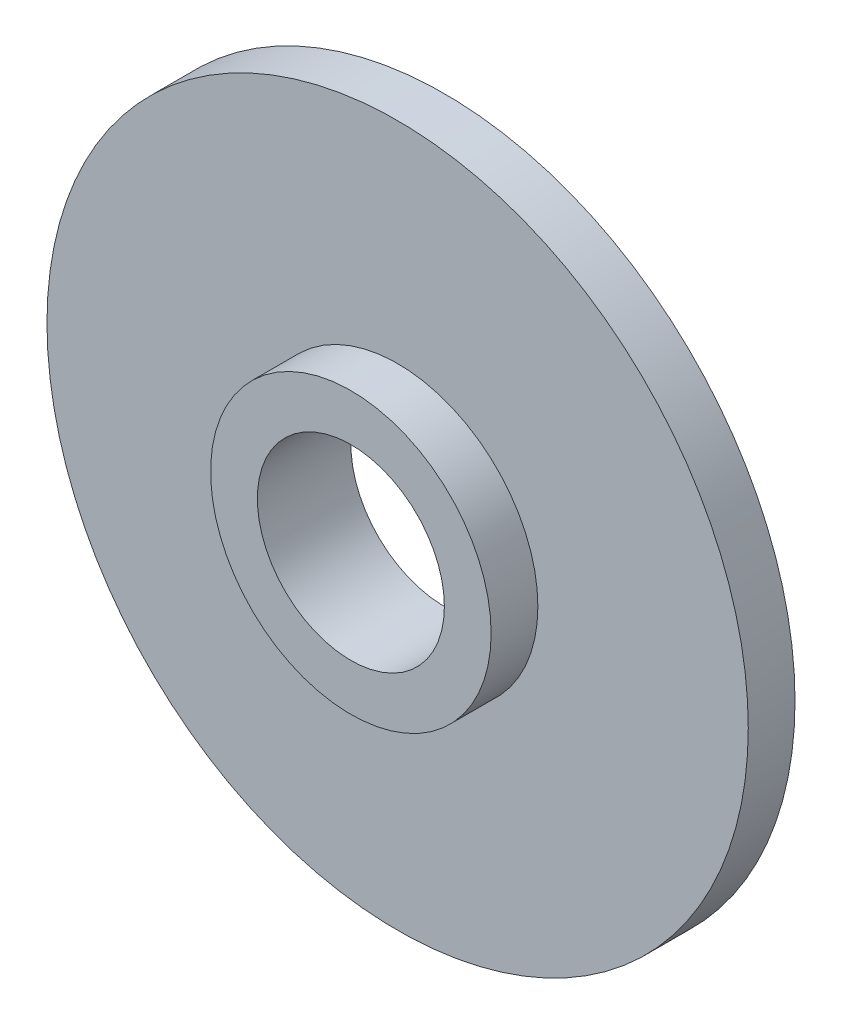
from build123d import *

# Parameters (mm, degrees)
SKETCH1_R      = 7.5
SKETCH1_R_2    = 2
EXTRUDE1_DEPTH = 1
SKETCH2_R      = 3
SKETCH2_R_2    = 2
EXTRUDE2_DEPTH = 1


with BuildPart() as part:
    # Sketch1 → Extrude1 (new body)
    with BuildSketch(Plane.XY):
        Circle(SKETCH1_R)
        Circle(SKETCH1_R_2, mode=Mode.SUBTRACT)
    extrude(amount=EXTRUDE1_DEPTH)

    # Sketch2 → Extrude2 (add)
    with BuildSketch(Plane.XY.offset(1)):
        Circle(SKETCH2_R)
        Circle(SKETCH2_R_2, mode=Mode.SUBTRACT)
    extrude(amount=EXTRUDE2_DEPTH)


solid = part.part
